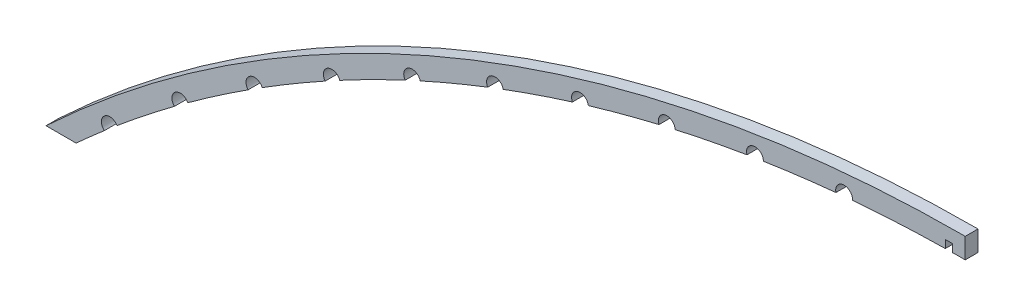
from build123d import *

# Parameters (mm, degrees)
EXTRUDE1_DEPTH      = 3.175
SKETCH3_R           = 2.0955
EXTRUDE2_DEPTH      = 4.175
CIRPATTERN1_COUNT   = 10
CIRPATTERN1_ANGLE   = 35
EXTRUDE3_DEPTH      = 1
EXTRUDE3_DEPTH_BACK = 4.175
SKETCH5_W           = 1.778
SKETCH5_H           = 1.961783436
EXTRUDE4_DEPTH      = 4.175


with BuildPart() as part:
    # Sketch1 → Extrude1 (new body)
    with BuildSketch(Plane.XY):
        with BuildLine():
            Line((0, 0), (228.6, 0))
            Line((228.6, 0), (228.6, 90.4875))
            ThreePointArc((228.6, 90.4875), (105.671212021, 67.042793316), (0, 0))
        make_face()
        with BuildLine():
            Line((40.029392194, 9.525), (209.55, 9.525))
            ThreePointArc((209.55, 9.525), (216.285192091, 12.314807909), (219.075, 19.05))
            Line((219.075, 19.05), (219.075, 74.358899247))
            ThreePointArc((219.075, 74.358899247), (218.099794794, 76.648337576), (215.773250164, 77.531368235))
            ThreePointArc((215.773250164, 77.531368235), (122.297861029, 59.693048715), (38.147400573, 15.25709455))
            ThreePointArc((38.147400573, 15.25709455), (37.012821277, 11.709583471), (40.029392194, 9.525))
        make_face(mode=Mode.SUBTRACT)
    extrude(amount=EXTRUDE1_DEPTH)

    # Sketch3 → Extrude2 (cut, through all)
    with BuildSketch(Plane.XY.offset(3.175)):
        with Locations((15.875, 7.775506467)):
            Circle(SKETCH3_R)
    extrude2 = extrude(amount=-EXTRUDE2_DEPTH, mode=Mode.SUBTRACT)

    # CirPattern1: Extrude2 ×10 about axis
    cirpattern1_axis = Axis((228.6, -243.514144737, 0), (0, 0, -1))
    for i in range(1, CIRPATTERN1_COUNT):
        add(extrude2.rotate(cirpattern1_axis, i * CIRPATTERN1_ANGLE / (CIRPATTERN1_COUNT - 1)), mode=Mode.SUBTRACT)

    # Sketch4 → Extrude3 (cut, two sides)
    with BuildSketch(Plane.XY.offset(3.175)) as extrude3_sk:
        with BuildLine():
            Line((726.667212815, 85.4075), (228.6, 85.4075))
            ThreePointArc((228.6, 85.4075), (107.540898152, 62.319375722), (3.476893058, -3.703729831))
            Line((3.476893058, -3.703729831), (-359.654286867, -344.594760291))
            Line((-359.654286867, -344.594760291), (6.971445482, -1270.807136749))
            Line((6.971445482, -1270.807136749), (1093.292945163, -840.804876459))
            Line((1093.292945163, -840.804876459), (726.667212815, 85.4075))
        make_face()
    extrude(amount=EXTRUDE3_DEPTH, mode=Mode.SUBTRACT)
    extrude(extrude3_sk.sketch, amount=-EXTRUDE3_DEPTH_BACK, mode=Mode.SUBTRACT)

    # Sketch5 → Extrude4 (cut, through all)
    with BuildSketch(Plane.XY.offset(3.175)):
        with Locations((224.536, 86.35109773)):
            Rectangle(SKETCH5_W, SKETCH5_H)
    extrude(amount=-EXTRUDE4_DEPTH, mode=Mode.SUBTRACT)


solid = part.part
